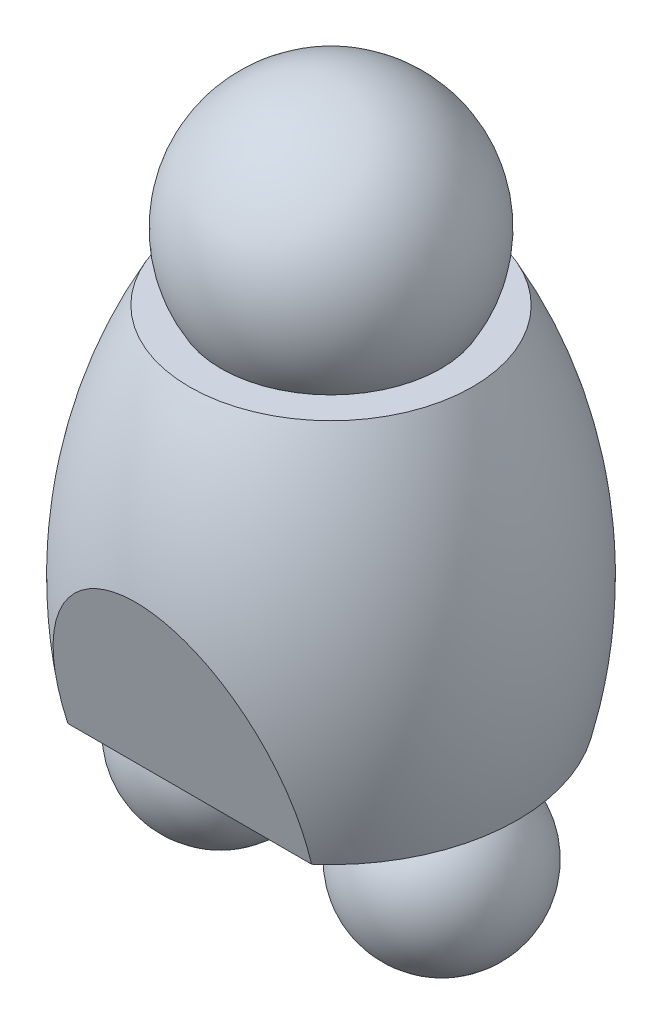
from build123d import *

# Parameters (mm, degrees)
CUT_EXTRUDE1_DEPTH = 15.976868681
SCALE1_SCALE       = 5.55


with BuildPart() as part:
    # Sketch1 → Base-Revolve (revolve)
    with BuildSketch(Plane.XY):
        with BuildLine():
            Line((0, 17.399), (0, -17.399))
            Line((0, -17.399), (18.415, -17.399))
            ThreePointArc((18.415, -17.399), (19.460122177, 0.417396993), (13.97, 17.399))
            Line((13.97, 17.399), (0, 17.399))
        make_face()
    revolve(axis=Axis((0, 64.099865047, 0), (0, -1, 0)))

    # Sketch2 → Cut-Extrude1 (cut, symmetric)
    with BuildSketch(Plane(origin=(0, 0, 0), x_dir=(0, 0, -1), z_dir=(1, 0, 0))):
        Polygon((-13.944000247, -17.399), (-19.286363897, 1.651), (-22.841821799, 1.651), (-22.841821799, -17.894237605), (-13.944000247, -17.894237605), align=None)
        Polygon((19.796019511, -3.429), (22.737840025, -3.429), (22.737840025, -17.894237605), (14.094585635, -17.894237605), (14.094585635, -17.399), align=None)
    extrude(amount=CUT_EXTRUDE1_DEPTH, both=True, mode=Mode.SUBTRACT)

    # Sketch3 → Boss-Revolve1 (revolve)
    with BuildSketch(Plane.XY):
        with BuildLine():
            Line((0, 36.703), (0, 11.303))
            ThreePointArc((0, 11.303), (12.7, 24.003), (0, 36.703))
        make_face()
    revolve(axis=Axis((0, 0, 0), (0, 1, 0)))

    # Sketch5 → Boss-Revolve2 (revolve)
    with BuildSketch(Plane.XY):
        with BuildLine():
            Line((10.922, -16.2306), (10.922, -32.7914))
            ThreePointArc((10.922, -32.7914), (19.2024, -24.511), (10.922, -16.2306))
        make_face()
    boss_revolve2 = revolve(axis=Axis((10.922, -36.241550195, 0), (0, 1, 0)))

    # Mirror1: Boss-Revolve2 across plane
    add(boss_revolve2.mirror(Plane(origin=(0, 0, 0), x_dir=(0, 0, 1), z_dir=(1, 0, 0))))


with BuildPart() as part_1:
    # Scale1: scaled about (-1.79e-07, 0.806776092, -0.114453365)
    add(part.part.scale(SCALE1_SCALE).moved(Location((8.14e-07, -3.670831219, 0.520762811))))


solid = part_1.part
